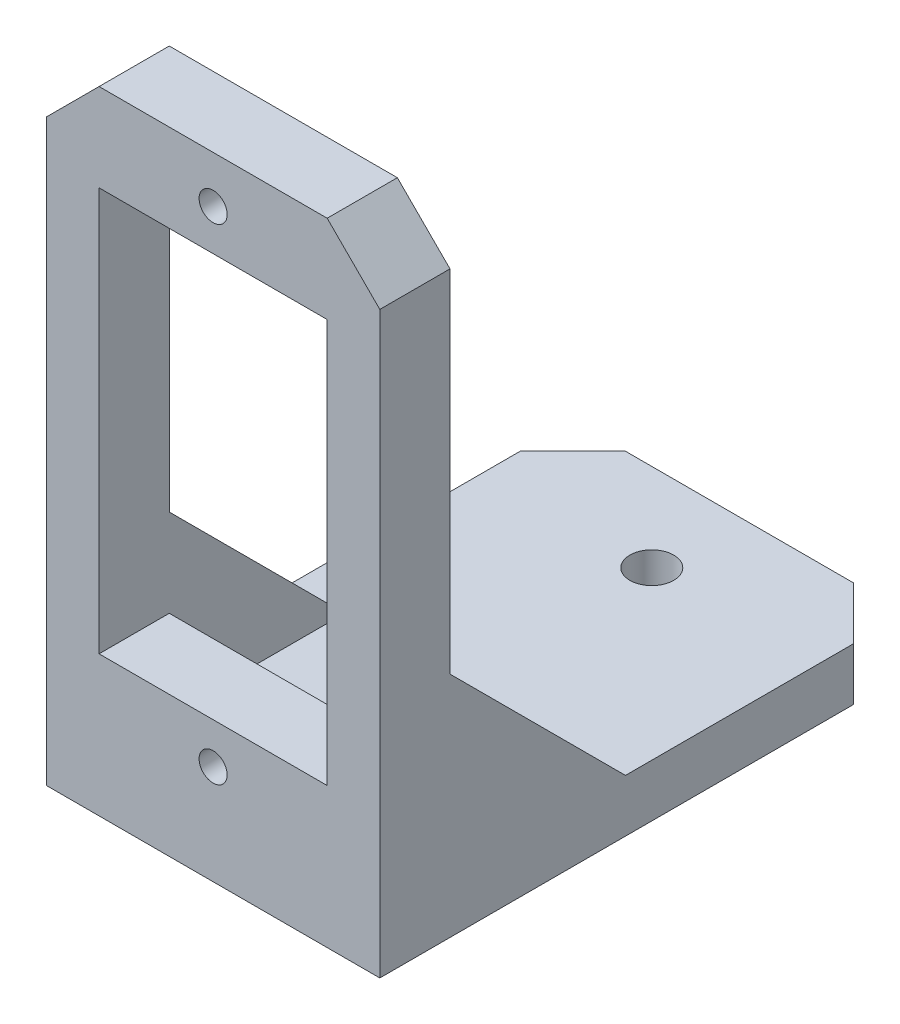
from build123d import *

# Parameters (mm, degrees)
CROQUIS1_W              = 19
CROQUIS1_H              = 33
SALIENTE_EXTRUIR1_DEPTH = 4
CROQUIS2_R              = 0.8
CROQUIS2_W              = 13
CROQUIS2_H              = 23
CORTAR_EXTRUIR1_DEPTH   = 5
CHAFL_N1_SIZE           = 3
CROQUIS3_W              = 19
CROQUIS3_H              = 3
SALIENTE_EXTRUIR2_DEPTH = 30
SALIENTE_EXTRUIR3_DEPTH = 3
SALIENTE_EXTRUIR4_DEPTH = 3
CHAFL_N2_SIZE           = 3
CROQUIS9_R              = 1.25
CORTAR_EXTRUIR2_DEPTH   = 3


with BuildPart() as part:
    # Croquis1 → Saliente-Extruir1 (new body)
    with BuildSketch(Plane.XY):
        Rectangle(CROQUIS1_W, CROQUIS1_H)
    extrude(amount=SALIENTE_EXTRUIR1_DEPTH)

    # Croquis2 → Cortar-Extruir1 (cut)
    with BuildSketch(Plane.XY.offset(4)):
        with Locations((0, 13.83)):
            Circle(CROQUIS2_R)
        with Locations((0, -13.83)):
            Circle(CROQUIS2_R)
        Rectangle(CROQUIS2_W, CROQUIS2_H)
    extrude(amount=-CORTAR_EXTRUIR1_DEPTH, mode=Mode.SUBTRACT)

    # Chaflán1
    chafl_n1_edges = [part.edges().sort_by_distance(p)[0] for p in [
        (-9.5, 16.5, 2),
        (9.5, 16.5, 2),
    ]]
    chamfer(chafl_n1_edges, length=CHAFL_N1_SIZE)

    # Croquis3 → Saliente-Extruir2 (add)
    with BuildSketch(Plane.XY.offset(4)):
        with Locations((0, -18)):
            Rectangle(CROQUIS3_W, CROQUIS3_H)
    extrude(amount=-SALIENTE_EXTRUIR2_DEPTH)

    # Croquis7 → Saliente-Extruir3 (add)
    with BuildSketch(Plane(origin=(9.5, 0, 0), x_dir=(0, 0, -1), z_dir=(1, 0, 0))):
        Polygon((0, -6.5), (0, -16.5), (10, -16.5), align=None)
    extrude(amount=-SALIENTE_EXTRUIR3_DEPTH)

    # Croquis8 → Saliente-Extruir4 (add)
    with BuildSketch(Plane.ZY.offset(9.5)):
        Polygon((0, -16.5), (-10, -16.5), (0, -6.5), align=None)
    extrude(amount=-SALIENTE_EXTRUIR4_DEPTH)

    # Chaflán2
    chafl_n2_edges = [part.edges().sort_by_distance(p)[0] for p in [
        (-9.5, -18, -26),
        (9.5, -18, -26),
    ]]
    chamfer(chafl_n2_edges, length=CHAFL_N2_SIZE)

    # Croquis9 → Cortar-Extruir2 (cut)
    with BuildSketch(Plane(origin=(0, -16.5, 0), x_dir=(1, 0, 0), z_dir=(0, 1, 0))):
        with Locations((0, 6)):
            Circle(CROQUIS9_R)
        with Locations((0, 21)):
            Circle(CROQUIS9_R)
    extrude(amount=-CORTAR_EXTRUIR2_DEPTH, mode=Mode.SUBTRACT)


solid = part.part
